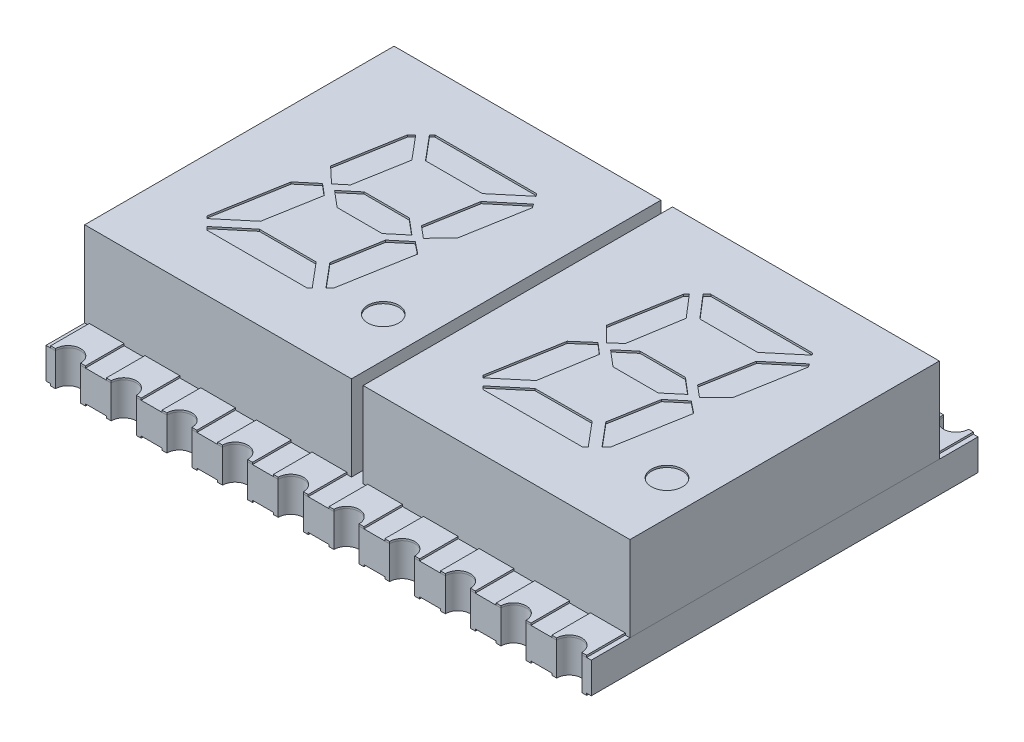
from build123d import *

# Parameters (mm, degrees)
SKETCH1_W          = 14.1
SKETCH1_H          = 8
EXTRUDE2_DEPTH     = 2.2
SKETCH6_R          = 0.4
CUT_EXTRUDE4_DEPTH = 0.05
SKETCH9_W          = 14.1
SKETCH9_H          = 10
EXTRUDE3_DEPTH     = 0.8
EXTRUDE4_DEPTH     = 0.05
EXTRUDE4_2_DEPTH   = 0.05
EXTRUDE4_3_DEPTH   = 0.05
EXTRUDE4_4_DEPTH   = 0.05
EXTRUDE4_5_DEPTH   = 0.05
EXTRUDE4_6_DEPTH   = 0.05
EXTRUDE4_7_DEPTH   = 0.05
EXTRUDE4_8_DEPTH   = 0.05
EXTRUDE4_9_DEPTH   = 0.05
EXTRUDE4_10_DEPTH  = 0.05
EXTRUDE4_11_DEPTH  = 0.05
EXTRUDE4_12_DEPTH  = 0.05
EXTRUDE4_13_DEPTH  = 0.05
EXTRUDE4_14_DEPTH  = 0.05
EXTRUDE4_15_DEPTH  = 0.05
EXTRUDE4_16_DEPTH  = 0.05
EXTRUDE4_17_DEPTH  = 0.05
EXTRUDE4_18_DEPTH  = 0.05
EXTRUDE4_19_DEPTH  = 0.05
EXTRUDE4_20_DEPTH  = 0.05
SKETCH11_W         = 0.9
SKETCH11_H         = 1.2
EXTRUDE5_DEPTH     = 0.05
SKETCH10_5_R       = 0.325
CUT_EXTRUDE6_DEPTH = 1.85
CUT_EXTRUDE7_START = -3.05
SKETCH13_W         = 0.3
SKETCH13_H         = 8
CUT_EXTRUDE7_DEPTH = 3.05


with BuildPart() as part:
    # Sketch1 → Extrude2 (new body)
    with BuildSketch(Plane(origin=(0, 0, 0), x_dir=(1, 0, 0), z_dir=(0, 1, 0))):
        Rectangle(SKETCH1_W, SKETCH1_H)
    extrude(amount=-EXTRUDE2_DEPTH)

    # Sketch6 → Cut-Extrude4 (cut)
    with BuildSketch(Plane(origin=(0, 0, 0), x_dir=(-1, 0, 0), z_dir=(0, 1, 0))):
        Polygon((4.782748397, -2.292928938), (4.889230725, -2.186446609), (5.187227717, -0.496421684), (4.773067161, -0.106096459), (4.50569461, -0.330448668), (4.267855181, -1.679303098), align=None)
        Polygon((4.535677334, -2.54), (4.605296443, -2.470380891), (4.07634407, -1.84), (2.606217558, -1.84), (1.853021687, -2.472006377), (1.900631335, -2.54), align=None)
        Polygon((4.899507997, 0), (5.339922125, 0.369551332), (5.666523883, 2.221801948), (5.607830565, 2.280495267), (4.854634694, 1.648488889), (4.60720899, 0.245267989), align=None)
        Polygon((4.171249474, -0.35), (4.588363232, 0), (4.171249474, 0.35), (3.005476989, 0.35), (2.588363232, 0), (3.005476989, -0.35), align=None)
        Polygon((1.709079836, -2.266436109), (2.445520656, -1.648488889), (2.677038056, -0.33548847), (2.36744488, -0.07570895), (1.933044827, -0.523744402), (1.642521938, -2.17138158), align=None)
        Polygon((4.693937792, 1.84), (5.430378612, 2.45794722), (5.348325832, 2.54), (2.764478016, 2.54), (2.694858907, 2.470380891), (3.22381128, 1.84), align=None)
        Polygon((2.815893942, 0.452002392), (3.032300169, 1.679303098), (2.517406953, 2.292928938), (2.410924625, 2.186446609), (2.087109539, 0.35), (2.398780184, 0.102002392), align=None)
        Polygon((-1.949461148, -0.496421684), (-2.337664882, -0.102128526), (-2.600723488, -0.331523742), (-2.8212107, -1.683323008), (-2.322915293, -2.261903762), (-2.247458141, -2.186446609), align=None)
        Polygon((-2.506615363, 0.245449828), (-2.222773925, -0.001940069), (-1.796766741, 0.369551332), (-1.470164982, 2.221801948), (-1.527756189, 2.279393156), (-2.27747441, 1.650304874), align=None)
        Polygon((-3.010641067, -1.846467532), (-3.007968533, -1.844165845), (-4.508315732, -1.842250325), (-5.274474949, -2.485134242), (-5.236057531, -2.54), (-2.601011531, -2.54), (-2.500182596, -2.439171065), align=None)
        Polygon((-3.910027343, 1.837442192), (-2.440167411, 1.844194842), (-1.707412365, 2.459049331), (-1.788363034, 2.54), (-4.37221085, 2.54), (-4.44144717, 2.470763679), align=None)
        Polygon((-5.436801259, -2.253308245), (-4.69203605, -1.628376033), (-4.461770738, -0.338004485), (-4.77030395, -0.076966958), (-5.203644039, -0.523744402), (-5.494166927, -2.17138158), align=None)
        Polygon((-4.320794924, 0.452002392), (-4.102364686, 1.676051998), (-4.619664701, 2.292546149), (-4.72576424, 2.186446609), (-5.049579326, 0.35), (-4.737908681, 0.102002392), align=None)
        Polygon((-4.134643259, 0.35), (-4.548325634, 0), (-4.134643259, -0.35), (-2.962008008, -0.35), (-2.548325634, 0), (-2.962008008, 0.35), align=None)
        with Locations(Location((1.188363232, 2.14, 0), (0, 0, 90))):  # turned: the seam where the file's is
            Circle(SKETCH6_R)
        with Locations(Location((-6.148325634, 2.14, 0), (0, 0, 90))):  # turned: the seam where the file's is
            Circle(SKETCH6_R)
    extrude(amount=-CUT_EXTRUDE4_DEPTH, mode=Mode.SUBTRACT)

    # Sketch13 → Cut-Extrude7 (cut)
    with BuildSketch(Plane(origin=(0, 0, 0), x_dir=(-1, 0, 0), z_dir=(0, 1, 0)).offset(CUT_EXTRUDE7_START)):
        Rectangle(SKETCH13_W, SKETCH13_H)
    extrude(amount=CUT_EXTRUDE7_DEPTH, mode=Mode.SUBTRACT)


with BuildPart() as body_2:
    # Sketch9 → Extrude3 (new body)
    with BuildSketch(Plane.XZ.offset(2.2)):
        Rectangle(SKETCH9_W, SKETCH9_H)
    extrude(amount=EXTRUDE3_DEPTH)

    # Sketch11 → Extrude5 (add)
    with BuildSketch(Plane.XZ.offset(3)):
        with Locations((-6.48, 4.4)):
            Rectangle(SKETCH11_W, SKETCH11_H)
        with Locations((-5.04, 4.4)):
            Rectangle(SKETCH11_W, SKETCH11_H)
        with Locations((-2.16, 4.4)):
            Rectangle(SKETCH11_W, SKETCH11_H)
        with Locations((0.72, 4.4)):
            Rectangle(SKETCH11_W, SKETCH11_H)
        with Locations((2.16, 4.4)):
            Rectangle(SKETCH11_W, SKETCH11_H)
        with Locations((3.6, 4.4)):
            Rectangle(SKETCH11_W, SKETCH11_H)
        with Locations((5.04, 4.4)):
            Rectangle(SKETCH11_W, SKETCH11_H)
        with Locations((6.48, 4.4)):
            Rectangle(SKETCH11_W, SKETCH11_H)
        with Locations((0.72, -4.4)):
            Rectangle(SKETCH11_W, SKETCH11_H)
        with Locations((2.16, -4.4)):
            Rectangle(SKETCH11_W, SKETCH11_H)
        with Locations((3.6, -4.4)):
            Rectangle(SKETCH11_W, SKETCH11_H)
        with Locations((5.04, -4.4)):
            Rectangle(SKETCH11_W, SKETCH11_H)
        with Locations((6.48, -4.4)):
            Rectangle(SKETCH11_W, SKETCH11_H)
        with Locations((-3.6, 4.4)):
            Rectangle(SKETCH11_W, SKETCH11_H)
        with Locations((-0.72, 4.4)):
            Rectangle(SKETCH11_W, SKETCH11_H)
        with Locations((-6.48, -4.4)):
            Rectangle(SKETCH11_W, SKETCH11_H)
        with Locations((-5.04, -4.4)):
            Rectangle(SKETCH11_W, SKETCH11_H)
        with Locations((-3.6, -4.4)):
            Rectangle(SKETCH11_W, SKETCH11_H)
        with Locations((-2.16, -4.4)):
            Rectangle(SKETCH11_W, SKETCH11_H)
        with Locations((-0.72, -4.4)):
            Rectangle(SKETCH11_W, SKETCH11_H)
    extrude(amount=EXTRUDE5_DEPTH)

    # Sketch10_5 → Cut-Extrude6 (cut, through all)
    with BuildSketch(Plane(origin=(0, -2.2, 0), x_dir=(-1, 0, 0), z_dir=(0, 1, 0))):
        with Locations((6.48, 5)):
            Circle(SKETCH10_5_R)
        with Locations((5.04, 5)):
            Circle(SKETCH10_5_R)
        with Locations((3.6, 5)):
            Circle(SKETCH10_5_R)
        with Locations((2.16, 5)):
            Circle(SKETCH10_5_R)
        with Locations((0.72, 5)):
            Circle(SKETCH10_5_R)
        with Locations((-0.72, 5)):
            Circle(SKETCH10_5_R)
        with Locations((-2.16, 5)):
            Circle(SKETCH10_5_R)
        with Locations((-3.6, 5)):
            Circle(SKETCH10_5_R)
        with Locations((-5.04, 5)):
            Circle(SKETCH10_5_R)
        with Locations((-6.48, 5)):
            Circle(SKETCH10_5_R)
        with Locations((-6.48, -5)):
            Circle(SKETCH10_5_R)
        with Locations((-5.04, -5)):
            Circle(SKETCH10_5_R)
        with Locations((-3.6, -5)):
            Circle(SKETCH10_5_R)
        with Locations((-2.16, -5)):
            Circle(SKETCH10_5_R)
        with Locations((-0.72, -5)):
            Circle(SKETCH10_5_R)
        with Locations((0.72, -5)):
            Circle(SKETCH10_5_R)
        with Locations((2.16, -5)):
            Circle(SKETCH10_5_R)
        with Locations((3.6, -5)):
            Circle(SKETCH10_5_R)
        with Locations((5.04, -5)):
            Circle(SKETCH10_5_R)
        with Locations((6.48, -5)):
            Circle(SKETCH10_5_R)
    extrude(amount=-CUT_EXTRUDE6_DEPTH, mode=Mode.SUBTRACT)


with BuildPart() as body_3:
    # Sketch10 → Extrude4 (new body)
    with BuildSketch(Plane(origin=(0, -2.2, 0), x_dir=(-1, 0, 0), z_dir=(0, 1, 0))):
        with BuildLine():
            Line((6.03, -4), (6.03, -5))
            Line((6.03, -5), (6.155, -5))
            ThreePointArc((6.155, -5), (6.48, -4.675), (6.805, -5))
            Line((6.805, -5), (6.93, -5))
            Line((6.93, -5), (6.93, -4))
            Line((6.93, -4), (6.03, -4))
        make_face()
    extrude(amount=EXTRUDE4_DEPTH)


with BuildPart() as body_4:
    # Sketch10 → Extrude4 2 (new body)
    with BuildSketch(Plane(origin=(0, -2.2, 0), x_dir=(-1, 0, 0), z_dir=(0, 1, 0))):
        with BuildLine():
            Line((4.59, -4), (4.59, -5))
            Line((4.59, -5), (4.715, -5))
            ThreePointArc((4.715, -5), (5.04, -4.675), (5.365, -5))
            Line((5.365, -5), (5.49, -5))
            Line((5.49, -5), (5.49, -4))
            Line((5.49, -4), (4.59, -4))
        make_face()
    extrude(amount=EXTRUDE4_2_DEPTH)


with BuildPart() as body_5:
    # Sketch10 → Extrude4 3 (new body)
    with BuildSketch(Plane(origin=(0, -2.2, 0), x_dir=(-1, 0, 0), z_dir=(0, 1, 0))):
        with BuildLine():
            Line((3.15, -4), (3.15, -5))
            Line((3.15, -5), (3.275, -5))
            ThreePointArc((3.275, -5), (3.6, -4.675), (3.925, -5))
            Line((3.925, -5), (4.05, -5))
            Line((4.05, -5), (4.05, -4))
            Line((4.05, -4), (3.15, -4))
        make_face()
    extrude(amount=EXTRUDE4_3_DEPTH)


with BuildPart() as body_6:
    # Sketch10 → Extrude4 4 (new body)
    with BuildSketch(Plane(origin=(0, -2.2, 0), x_dir=(-1, 0, 0), z_dir=(0, 1, 0))):
        with BuildLine():
            Line((1.71, -4), (1.71, -5))
            Line((1.71, -5), (1.835, -5))
            ThreePointArc((1.835, -5), (2.16, -4.675), (2.485, -5))
            Line((2.485, -5), (2.61, -5))
            Line((2.61, -5), (2.61, -4))
            Line((2.61, -4), (1.71, -4))
        make_face()
    extrude(amount=EXTRUDE4_4_DEPTH)


with BuildPart() as body_7:
    # Sketch10 → Extrude4 5 (new body)
    with BuildSketch(Plane(origin=(0, -2.2, 0), x_dir=(-1, 0, 0), z_dir=(0, 1, 0))):
        with BuildLine():
            Line((0.27, -4), (0.27, -5))
            Line((0.27, -5), (0.395, -5))
            ThreePointArc((0.395, -5), (0.72, -4.675), (1.045, -5))
            Line((1.045, -5), (1.17, -5))
            Line((1.17, -5), (1.17, -4))
            Line((1.17, -4), (0.27, -4))
        make_face()
    extrude(amount=EXTRUDE4_5_DEPTH)


with BuildPart() as body_8:
    # Sketch10 → Extrude4 6 (new body)
    with BuildSketch(Plane(origin=(0, -2.2, 0), x_dir=(-1, 0, 0), z_dir=(0, 1, 0))):
        with BuildLine():
            Line((6.03, 4), (6.93, 4))
            Line((6.93, 4), (6.93, 5))
            Line((6.93, 5), (6.805, 5))
            ThreePointArc((6.805, 5), (6.48, 4.675), (6.155, 5))
            Line((6.155, 5), (6.03, 5))
            Line((6.03, 5), (6.03, 4))
        make_face()
    extrude(amount=EXTRUDE4_6_DEPTH)


with BuildPart() as body_9:
    # Sketch10 → Extrude4 7 (new body)
    with BuildSketch(Plane(origin=(0, -2.2, 0), x_dir=(-1, 0, 0), z_dir=(0, 1, 0))):
        with BuildLine():
            Line((5.49, 4), (5.49, 5))
            Line((5.49, 5), (5.365, 5))
            ThreePointArc((5.365, 5), (5.04, 4.675), (4.715, 5))
            Line((4.715, 5), (4.59, 5))
            Line((4.59, 5), (4.59, 4))
            Line((4.59, 4), (5.49, 4))
        make_face()
    extrude(amount=EXTRUDE4_7_DEPTH)


with BuildPart() as body_10:
    # Sketch10 → Extrude4 8 (new body)
    with BuildSketch(Plane(origin=(0, -2.2, 0), x_dir=(-1, 0, 0), z_dir=(0, 1, 0))):
        with BuildLine():
            Line((4.05, 4), (4.05, 5))
            Line((4.05, 5), (3.925, 5))
            ThreePointArc((3.925, 5), (3.6, 4.675), (3.275, 5))
            Line((3.275, 5), (3.15, 5))
            Line((3.15, 5), (3.15, 4))
            Line((3.15, 4), (4.05, 4))
        make_face()
    extrude(amount=EXTRUDE4_8_DEPTH)


with BuildPart() as body_11:
    # Sketch10 → Extrude4 9 (new body)
    with BuildSketch(Plane(origin=(0, -2.2, 0), x_dir=(-1, 0, 0), z_dir=(0, 1, 0))):
        with BuildLine():
            Line((2.61, 4), (2.61, 5))
            Line((2.61, 5), (2.485, 5))
            ThreePointArc((2.485, 5), (2.16, 4.675), (1.835, 5))
            Line((1.835, 5), (1.71, 5))
            Line((1.71, 5), (1.71, 4))
            Line((1.71, 4), (2.61, 4))
        make_face()
    extrude(amount=EXTRUDE4_9_DEPTH)


with BuildPart() as body_12:
    # Sketch10 → Extrude4 10 (new body)
    with BuildSketch(Plane(origin=(0, -2.2, 0), x_dir=(-1, 0, 0), z_dir=(0, 1, 0))):
        with BuildLine():
            Line((1.17, 4), (1.17, 5))
            Line((1.17, 5), (1.045, 5))
            ThreePointArc((1.045, 5), (0.72, 4.675), (0.395, 5))
            Line((0.395, 5), (0.27, 5))
            Line((0.27, 5), (0.27, 4))
            Line((0.27, 4), (1.17, 4))
        make_face()
    extrude(amount=EXTRUDE4_10_DEPTH)


with BuildPart() as body_13:
    # Sketch10 → Extrude4 11 (new body)
    with BuildSketch(Plane(origin=(0, -2.2, 0), x_dir=(-1, 0, 0), z_dir=(0, 1, 0))):
        with BuildLine():
            Line((-1.17, -4), (-1.17, -5))
            Line((-1.17, -5), (-1.045, -5))
            ThreePointArc((-1.045, -5), (-0.72, -4.675), (-0.395, -5))
            Line((-0.395, -5), (-0.27, -5))
            Line((-0.27, -5), (-0.27, -4))
            Line((-0.27, -4), (-1.17, -4))
        make_face()
    extrude(amount=EXTRUDE4_11_DEPTH)


with BuildPart() as body_14:
    # Sketch10 → Extrude4 12 (new body)
    with BuildSketch(Plane(origin=(0, -2.2, 0), x_dir=(-1, 0, 0), z_dir=(0, 1, 0))):
        with BuildLine():
            Line((-2.61, -4), (-2.61, -5))
            Line((-2.61, -5), (-2.485, -5))
            ThreePointArc((-2.485, -5), (-2.16, -4.675), (-1.835, -5))
            Line((-1.835, -5), (-1.71, -5))
            Line((-1.71, -5), (-1.71, -4))
            Line((-1.71, -4), (-2.61, -4))
        make_face()
    extrude(amount=EXTRUDE4_12_DEPTH)


with BuildPart() as body_15:
    # Sketch10 → Extrude4 13 (new body)
    with BuildSketch(Plane(origin=(0, -2.2, 0), x_dir=(-1, 0, 0), z_dir=(0, 1, 0))):
        with BuildLine():
            Line((-4.05, -4), (-4.05, -5))
            Line((-4.05, -5), (-3.925, -5))
            ThreePointArc((-3.925, -5), (-3.6, -4.675), (-3.275, -5))
            Line((-3.275, -5), (-3.15, -5))
            Line((-3.15, -5), (-3.15, -4))
            Line((-3.15, -4), (-4.05, -4))
        make_face()
    extrude(amount=EXTRUDE4_13_DEPTH)


with BuildPart() as body_16:
    # Sketch10 → Extrude4 14 (new body)
    with BuildSketch(Plane(origin=(0, -2.2, 0), x_dir=(-1, 0, 0), z_dir=(0, 1, 0))):
        with BuildLine():
            Line((-5.49, -4), (-5.49, -5))
            Line((-5.49, -5), (-5.365, -5))
            ThreePointArc((-5.365, -5), (-5.04, -4.675), (-4.715, -5))
            Line((-4.715, -5), (-4.59, -5))
            Line((-4.59, -5), (-4.59, -4))
            Line((-4.59, -4), (-5.49, -4))
        make_face()
    extrude(amount=EXTRUDE4_14_DEPTH)


with BuildPart() as body_17:
    # Sketch10 → Extrude4 15 (new body)
    with BuildSketch(Plane(origin=(0, -2.2, 0), x_dir=(-1, 0, 0), z_dir=(0, 1, 0))):
        with BuildLine():
            Line((-6.03, -4), (-6.93, -4))
            Line((-6.93, -4), (-6.93, -5))
            Line((-6.93, -5), (-6.805, -5))
            ThreePointArc((-6.805, -5), (-6.48, -4.675), (-6.155, -5))
            Line((-6.155, -5), (-6.03, -5))
            Line((-6.03, -5), (-6.03, -4))
        make_face()
    extrude(amount=EXTRUDE4_15_DEPTH)


with BuildPart() as body_18:
    # Sketch10 → Extrude4 16 (new body)
    with BuildSketch(Plane(origin=(0, -2.2, 0), x_dir=(-1, 0, 0), z_dir=(0, 1, 0))):
        with BuildLine():
            Line((-0.27, 4), (-0.27, 5))
            Line((-0.27, 5), (-0.395, 5))
            ThreePointArc((-0.395, 5), (-0.72, 4.675), (-1.045, 5))
            Line((-1.045, 5), (-1.17, 5))
            Line((-1.17, 5), (-1.17, 4))
            Line((-1.17, 4), (-0.27, 4))
        make_face()
    extrude(amount=EXTRUDE4_16_DEPTH)


with BuildPart() as body_19:
    # Sketch10 → Extrude4 17 (new body)
    with BuildSketch(Plane(origin=(0, -2.2, 0), x_dir=(-1, 0, 0), z_dir=(0, 1, 0))):
        with BuildLine():
            Line((-1.71, 4), (-1.71, 5))
            Line((-1.71, 5), (-1.835, 5))
            ThreePointArc((-1.835, 5), (-2.16, 4.675), (-2.485, 5))
            Line((-2.485, 5), (-2.61, 5))
            Line((-2.61, 5), (-2.61, 4))
            Line((-2.61, 4), (-1.71, 4))
        make_face()
    extrude(amount=EXTRUDE4_17_DEPTH)


with BuildPart() as body_20:
    # Sketch10 → Extrude4 18 (new body)
    with BuildSketch(Plane(origin=(0, -2.2, 0), x_dir=(-1, 0, 0), z_dir=(0, 1, 0))):
        with BuildLine():
            Line((-3.15, 4), (-3.15, 5))
            Line((-3.15, 5), (-3.275, 5))
            ThreePointArc((-3.275, 5), (-3.6, 4.675), (-3.925, 5))
            Line((-3.925, 5), (-4.05, 5))
            Line((-4.05, 5), (-4.05, 4))
            Line((-4.05, 4), (-3.15, 4))
        make_face()
    extrude(amount=EXTRUDE4_18_DEPTH)


with BuildPart() as body_21:
    # Sketch10 → Extrude4 19 (new body)
    with BuildSketch(Plane(origin=(0, -2.2, 0), x_dir=(-1, 0, 0), z_dir=(0, 1, 0))):
        with BuildLine():
            Line((-4.59, 4), (-4.59, 5))
            Line((-4.59, 5), (-4.715, 5))
            ThreePointArc((-4.715, 5), (-5.04, 4.675), (-5.365, 5))
            Line((-5.365, 5), (-5.49, 5))
            Line((-5.49, 5), (-5.49, 4))
            Line((-5.49, 4), (-4.59, 4))
        make_face()
    extrude(amount=EXTRUDE4_19_DEPTH)


with BuildPart() as body_22:
    # Sketch10 → Extrude4 20 (new body)
    with BuildSketch(Plane(origin=(0, -2.2, 0), x_dir=(-1, 0, 0), z_dir=(0, 1, 0))):
        with BuildLine():
            Line((-6.03, 4), (-6.03, 5))
            Line((-6.03, 5), (-6.155, 5))
            ThreePointArc((-6.155, 5), (-6.48, 4.675), (-6.805, 5))
            Line((-6.805, 5), (-6.93, 5))
            Line((-6.93, 5), (-6.93, 4))
            Line((-6.93, 4), (-6.03, 4))
        make_face()
    extrude(amount=EXTRUDE4_20_DEPTH)


solid = Compound([part.part, body_2.part, body_3.part, body_4.part, body_5.part, body_6.part, body_7.part, body_8.part, body_9.part, body_10.part, body_11.part, body_12.part, body_13.part, body_14.part, body_15.part, body_16.part, body_17.part, body_18.part, body_19.part, body_20.part, body_21.part, body_22.part])
